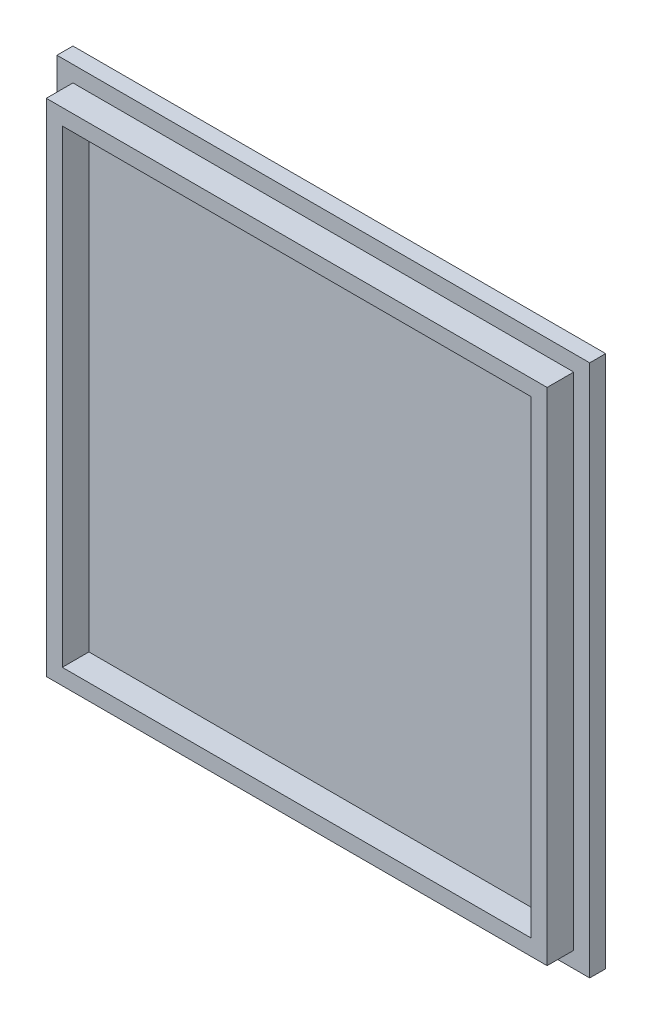
from build123d import *

# Parameters (mm, degrees)
SKETCH_1_W          = 100
SKETCH_1_H          = 100
EXTRUDE_3_DEPTH     = 8
SKETCH_4_W          = 100
SKETCH_4_H          = 100
SKETCH_4_W_2        = 94
SKETCH_4_H_2        = 94
SKETCH_4_W_3        = 88
SKETCH_4_H_3        = 88
CUT_EXTRUDE_3_DEPTH = 5


with BuildPart() as part:
    # 草图1 → 凸台-拉伸3 (new body)
    with BuildSketch(Plane.XY):
        with Locations((1.458885942, 2.519893899)):
            Rectangle(SKETCH_1_W, SKETCH_1_H)
    extrude(amount=EXTRUDE_3_DEPTH)

    # 草图4 → 切除-拉伸3 (cut)
    with BuildSketch(Plane.XY.offset(8)):
        with Locations((1.458885942, 2.519893899)):
            Rectangle(SKETCH_4_W, SKETCH_4_H)
        with Locations((1.458885942, 2.519893899)):
            Rectangle(SKETCH_4_W_2, SKETCH_4_H_2, mode=Mode.SUBTRACT)
        with Locations((1.458885942, 2.519893899)):
            Rectangle(SKETCH_4_W_3, SKETCH_4_H_3)
    extrude(amount=-CUT_EXTRUDE_3_DEPTH, mode=Mode.SUBTRACT)


solid = part.part
